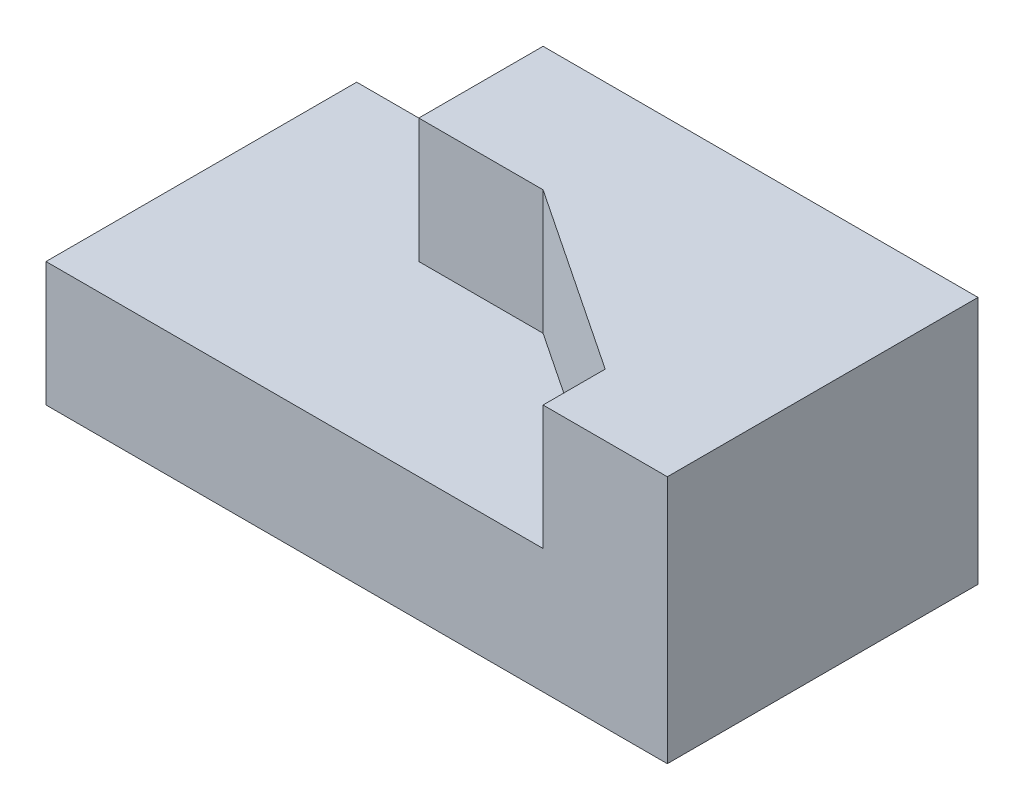
from build123d import *

# Parameters (mm, degrees)
SKETCH1_W           = 100
SKETCH1_H           = 50
BOSS_EXTRUDE1_DEPTH = 20
BOSS_EXTRUDE2_DEPTH = 20


with BuildPart() as part:
    # Sketch1 → Boss-Extrude1 (new body)
    with BuildSketch(Plane(origin=(0, 0, 0), x_dir=(1, 0, 0), z_dir=(0, 1, 0))):
        with Locations((50, 25)):
            Rectangle(SKETCH1_W, SKETCH1_H)
    extrude(amount=BOSS_EXTRUDE1_DEPTH)

    # Sketch2 → Boss-Extrude2 (add)
    with BuildSketch(Plane(origin=(0, 20, 0), x_dir=(1, 0, 0), z_dir=(0, 1, 0))):
        Polygon((30, 50), (30, 30), (50, 30), (80, 10), (80, 0), (100, 0), (100, 50), align=None)
    extrude(amount=BOSS_EXTRUDE2_DEPTH)


solid = part.part
